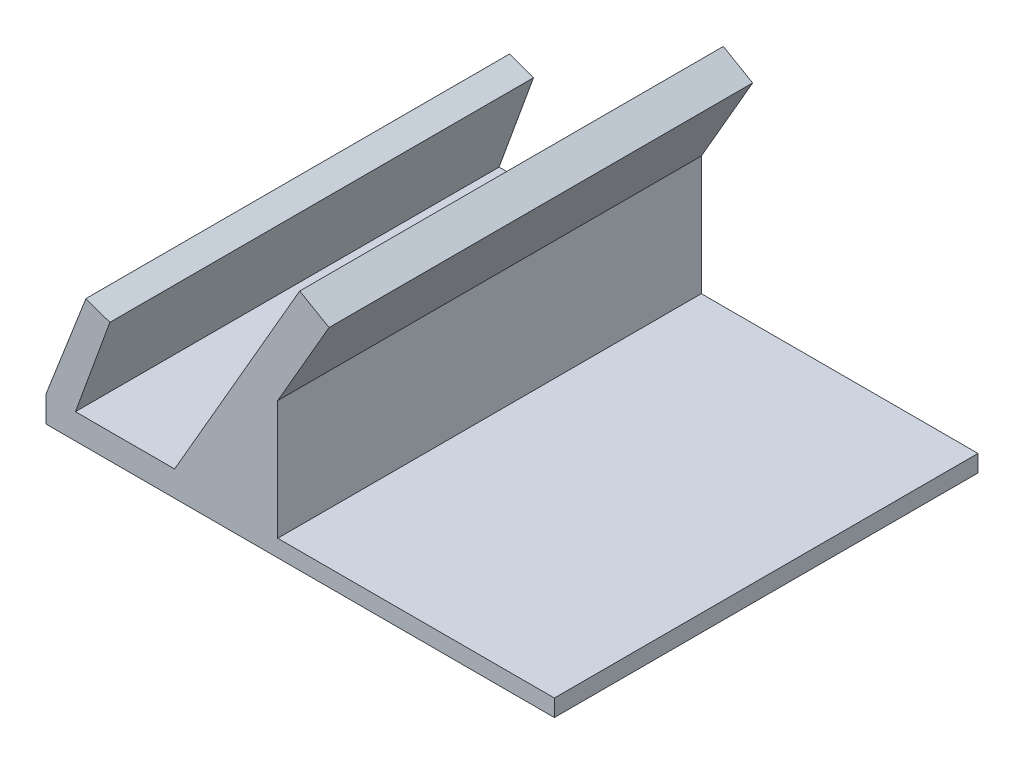
from build123d import *

# Parameters (mm, degrees)
SALIENTE_EXTRUIR1_DEPTH = 50
CROQUIS2_W              = 50
CROQUIS2_H              = 2
SALIENTE_EXTRUIR2_DEPTH = 20


with BuildPart() as part:
    # Croquis1 → Saliente-Extruir1 (new body)
    with BuildSketch(Plane.XY):
        Polygon((-84.492533904, -6.999380213), (-44.492533904, -6.999380213), (-44.492533904, -5.738560558), (-44.492533904, -4.999380213), (-45.492533904, -4.999380213), (-57.147376638, -4.999380213), (-57.147376638, 9.072422448), (-51.585761076, 18.705423174), (-51.085761076, 19.571448577), (-54.549862691, 21.571448577), (-69.313187577, -3.999380213), (-81.019143074, -3.999380213), (-80.530687688, -2.657360069), (-77.297371662, 6.226102703), (-76.955351518, 7.165795324), (-79.774429381, 8.191855754), (-80.129339821, 7.280632657), (-84.424349875, -3.746691195), (-84.492533904, -3.921751872), (-84.492533904, -4.109622312), align=None)
    extrude(amount=SALIENTE_EXTRUIR1_DEPTH)

    # Croquis2 → Saliente-Extruir2 (add)
    with BuildSketch(Plane(origin=(-44.492533904, 0, 0), x_dir=(0, 0, -1), z_dir=(1, 0, 0))):
        with Locations((-25, -5.999380213)):
            Rectangle(CROQUIS2_W, CROQUIS2_H)
    extrude(amount=SALIENTE_EXTRUIR2_DEPTH)


solid = part.part
